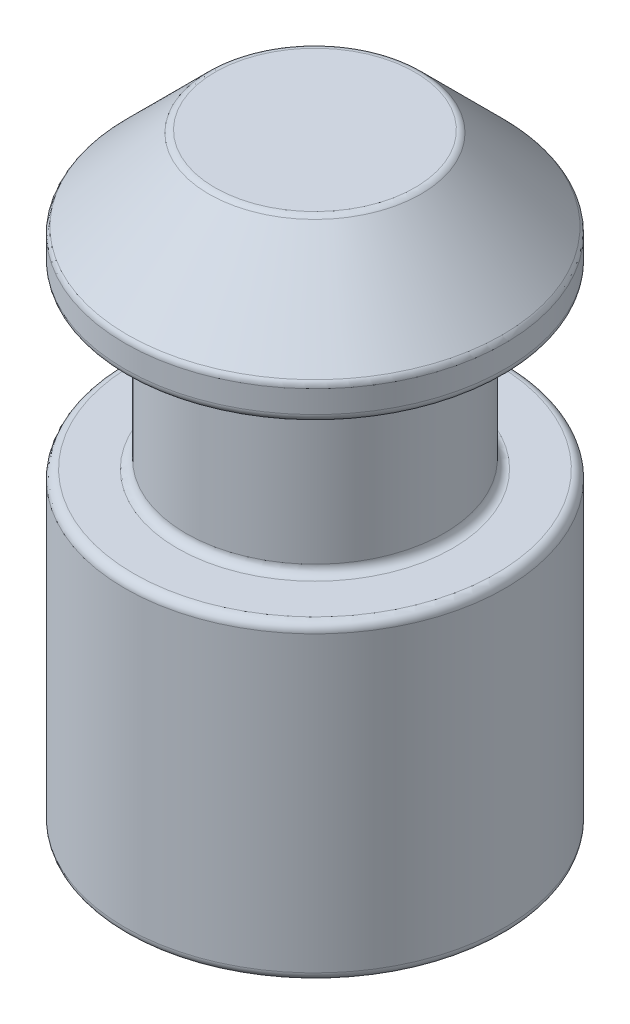
from build123d import *

# Parameters (mm, degrees)
SKETCH1_R           = 1.1
BOSS_EXTRUDE1_DEPTH = 3.5
CHAMFER1_SIZE       = 0.5
CUT_EXTRUDE1_START  = -0.7
SKETCH2_R           = 1.396092668
SKETCH2_R_2         = 0.747130163
CUT_EXTRUDE1_DEPTH  = 1
FILLET1_R           = 0.05


with BuildPart() as part:
    # Sketch1 → Boss-Extrude1 (new body)
    with BuildSketch(Plane(origin=(0, 0, 0), x_dir=(1, 0, 0), z_dir=(0, 1, 0))):
        Circle(SKETCH1_R)
    extrude(amount=BOSS_EXTRUDE1_DEPTH)

    # Chamfer1
    chamfer1_edges = [part.edges().sort_by_distance(p)[0] for p in [
        (-1.1, 3.5, 0),
    ]]
    chamfer(chamfer1_edges, length=CHAMFER1_SIZE)

    # Sketch2 → Cut-Extrude1 (cut)
    with BuildSketch(Plane(origin=(0, 3.5, 0), x_dir=(1, 0, 0), z_dir=(0, 1, 0)).offset(CUT_EXTRUDE1_START)):
        Circle(SKETCH2_R)
        Circle(SKETCH2_R_2, mode=Mode.SUBTRACT)
    extrude(amount=-CUT_EXTRUDE1_DEPTH, mode=Mode.SUBTRACT)

    # Fillet1
    fillet1_edges = [part.edges().sort_by_distance(p)[0] for p in [
        (-1.1, 2.8, 0),
        (-1.1, 1.8, 0),
        (-0.747130163, 2.8, 0),
        (-1.1, 0, 0),
        (-0.6, 3.5, 0),
        (-1.1, 3, 0),
        (-0.747130163, 1.8, 0),
    ]]
    fillet(fillet1_edges, radius=FILLET1_R)


solid = part.part
